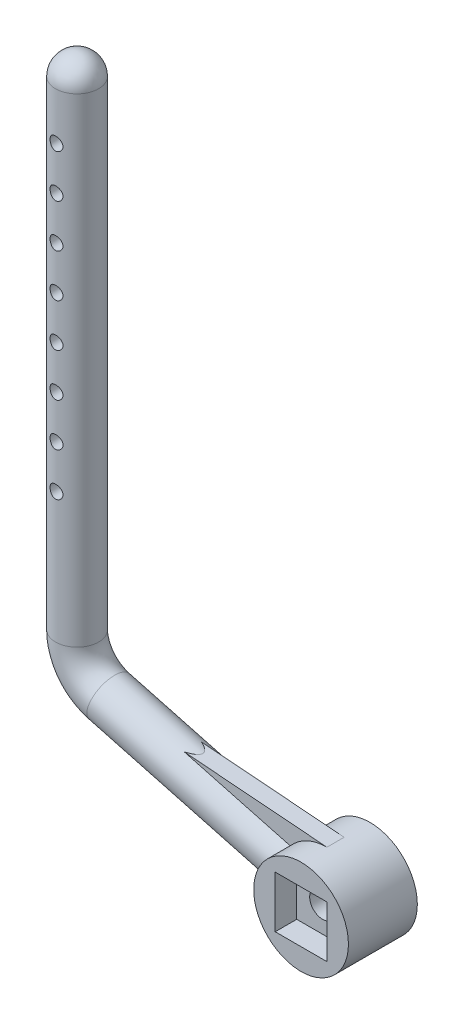
from build123d import *

# Parameters (mm, degrees)
ESQUISSE1_R             = 5.5
ESQUISSE1_W             = 6
ESQUISSE1_H             = 6
BASE_EXTRUSION_DEPTH    = 4
ESQUISSE2_W             = 6
ESQUISSE2_H             = 6
BOSS_EXTRU_1_DEPTH      = 1.5
ESQUISSE3_R             = 1.5
ENL_V_MAT_EXTRU_1_DEPTH = 6.5
ESQUISSE6_R             = 2.5
CONG_1_R                = 2.5
ESQUISSE7_R             = 0.75
ENL_V_MAT_EXTRU_2_DEPTH = 11.5
BOSS_EXTRU_2_DEPTH      = 1


with BuildPart() as part:
    # Esquisse1 → Base-Extrusion (new body, symmetric)
    with BuildSketch(Plane.XY):
        Circle(ESQUISSE1_R)
        Rectangle(ESQUISSE1_W, ESQUISSE1_H, mode=Mode.SUBTRACT)
    extrude(amount=BASE_EXTRUSION_DEPTH, both=True)

    # Esquisse2 → Boss.-Extru.1 (add, symmetric)
    with BuildSketch(Plane.XY):
        Rectangle(ESQUISSE2_W, ESQUISSE2_H)
    extrude(amount=BOSS_EXTRU_1_DEPTH, both=True)

    # Esquisse3 → Enl_v. mat.-Extru.1 (cut, through all)
    with BuildSketch(Plane.XY.offset(1.5)):
        Circle(ESQUISSE3_R)
    extrude(amount=-ENL_V_MAT_EXTRU_1_DEPTH, mode=Mode.SUBTRACT)

    # Boss.-Balayage1: sweep along a curve in space
    with BuildLine() as boss_balayage1_path:
        Line((-3.728314003, 0.998998726, 0), (-26.294095226, 7.045481581, 0))
        ThreePointArc((-26.294095226, 7.045481581, 0), (-28.966766701, 8.831303568, 0), (-30, 11.875110713, 0))
        Line((-30, 11.875110713, 0), (-30, 70, 0))
    # Esquisse6 → Boss.-Balayage1 (sweep)
    with BuildSketch(Plane(origin=(0, 70, 0), x_dir=(-1, 0, 0), z_dir=(0, 1, 0))):
        with Locations((30, 0)):
            Circle(ESQUISSE6_R)
    sweep(path=boss_balayage1_path.line)

    # Cong_1
    cong_1_edges = [part.edges().sort_by_distance(p)[0] for p in [
        (-27.5, 70, 0),
    ]]
    fillet(cong_1_edges, radius=CONG_1_R)

    # Esquisse7 → Enl_v. mat.-Extru.2 (cut, symmetric)
    with BuildSketch(Plane.XY):
        with Locations((-30, 27)):
            Circle(ESQUISSE7_R)
        with Locations((-30, 32)):
            Circle(ESQUISSE7_R)
        with Locations((-30, 37)):
            Circle(ESQUISSE7_R)
        with Locations((-30, 42)):
            Circle(ESQUISSE7_R)
        with Locations((-30, 47)):
            Circle(ESQUISSE7_R)
        with Locations((-30, 52)):
            Circle(ESQUISSE7_R)
        with Locations((-30, 57)):
            Circle(ESQUISSE7_R)
        with Locations((-30, 62)):
            Circle(ESQUISSE7_R)
    extrude(amount=ENL_V_MAT_EXTRU_2_DEPTH, both=True, mode=Mode.SUBTRACT)

    # Esquisse8 → Boss.-Extru.2 (add, symmetric)
    with BuildSketch(Plane.XY):
        Polygon((0, 5.5), (-19, 7), (-2, 2), align=None)
    extrude(amount=BOSS_EXTRU_2_DEPTH, both=True)


solid = part.part
